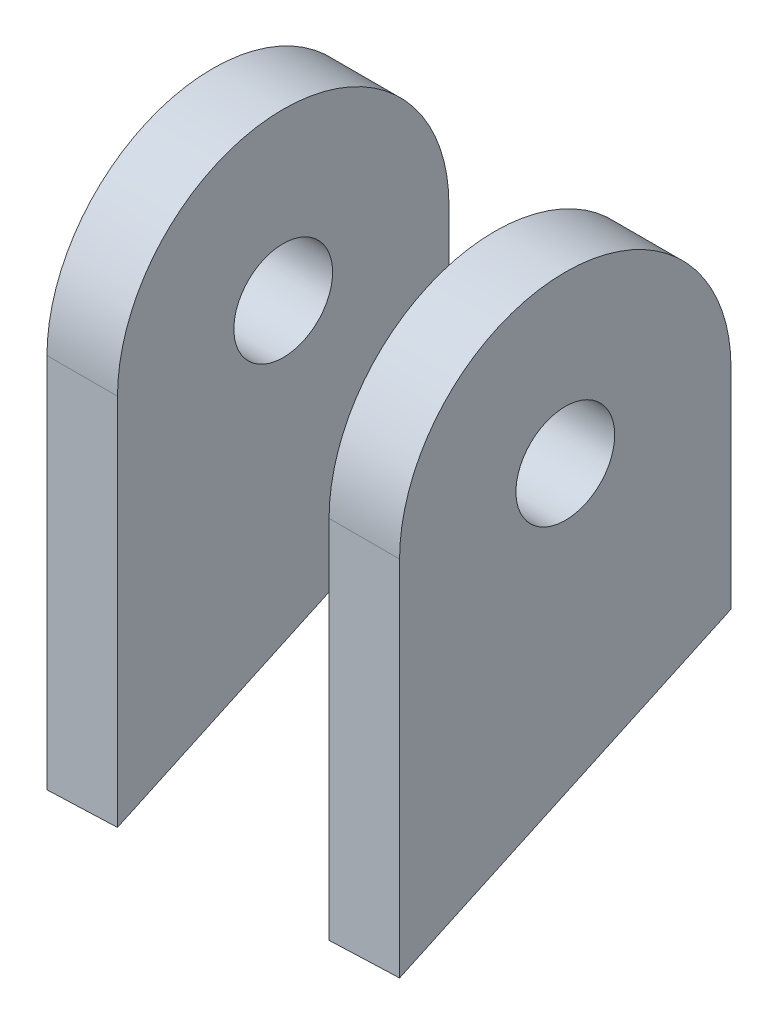
from build123d import *

# Parameters (mm, degrees)
EXTRUDE_1_DEPTH      = 10
EXTRUDE_1_DEPTH_BACK = 40
SKETCH_1_R           = 7
CUT_EXTRUDE_START    = -30
SKETCH_1_2_R         = 7
CUT_EXTRUDE_1_DEPTH  = 30
SKETCH_2_R           = 285.396943436
CUT_EXTRUDE_2_DEPTH  = 284.687476453


with BuildPart() as part:
    # 草图1 → 凸台-拉伸1 (new, two sides: drawn at the far end of the back side and taken through both)
    with BuildSketch(Plane(origin=(0, 0, 0), x_dir=(0, 0, -1), z_dir=(1, 0, 0)).offset(-EXTRUDE_1_DEPTH_BACK)):
        with BuildLine():
            Line((-23.5, 0), (-23.5, -107.176978603))
            Line((-23.5, -107.176978603), (23.5, -107.176978603))
            Line((23.5, -107.176978603), (23.5, 0))
            ThreePointArc((23.5, 0), (0, 23.5), (-23.5, 0))
        make_face()
        Circle(SKETCH_1_R, mode=Mode.SUBTRACT)
    extrude(amount=EXTRUDE_1_DEPTH + EXTRUDE_1_DEPTH_BACK)

    # 草图1<2> → 切除-拉伸1 (cut)
    with BuildSketch(Plane(origin=(0, 0, 0), x_dir=(0, 0, -1), z_dir=(1, 0, 0)).offset(CUT_EXTRUDE_START)):
        with BuildLine():
            Line((-23.5, 0), (-23.5, -107.176978603))
            Line((-23.5, -107.176978603), (23.5, -107.176978603))
            Line((23.5, -107.176978603), (23.5, 0))
            ThreePointArc((23.5, 0), (0, 23.5), (-23.5, 0))
        make_face()
        Circle(SKETCH_1_2_R, mode=Mode.SUBTRACT)
    extrude(amount=CUT_EXTRUDE_1_DEPTH, mode=Mode.SUBTRACT)


with BuildPart() as cut_extrude_1_piece_1:
    # of the separate pieces the step leaves, piece 1, a body of its own (cut_extrude_1_pieces)
    add(part.part.solids().sort_by_distance((10, 0, 23.5))[0])


with BuildPart() as cut_extrude_1_piece_2:
    # of the separate pieces the step leaves, piece 2, a body of its own (cut_extrude_1_pieces)
    add(part.part.solids().sort_by_distance((-30, 0, 23.5))[0])


with BuildPart() as cut_extrude_2_tool:
    # 草图2 → 切除-拉伸2 (new body)
    with BuildSketch(Plane(origin=(1.273035004, -33.642623321, -15.600983239), x_dir=(0.9994112974805099, 0.031124564928844464, 0.014433292289486975), z_dir=(-0.03430828570948451, 0.9066684964225279, 0.4204464045827826))):
        Circle(SKETCH_2_R)
    extrude(amount=-CUT_EXTRUDE_2_DEPTH)


with BuildPart() as cut_extrude_1_piece_1_1:
    add(cut_extrude_1_piece_1.part)

    # 切除-拉伸2: cut by cut_extrude_2_tool
    add(cut_extrude_2_tool.part, mode=Mode.SUBTRACT)


with BuildPart() as cut_extrude_1_piece_2_1:
    add(cut_extrude_1_piece_2.part)

    # 切除-拉伸2: cut by cut_extrude_2_tool
    add(cut_extrude_2_tool.part, mode=Mode.SUBTRACT)


solid = Compound([cut_extrude_1_piece_1_1.part, cut_extrude_1_piece_2_1.part])
